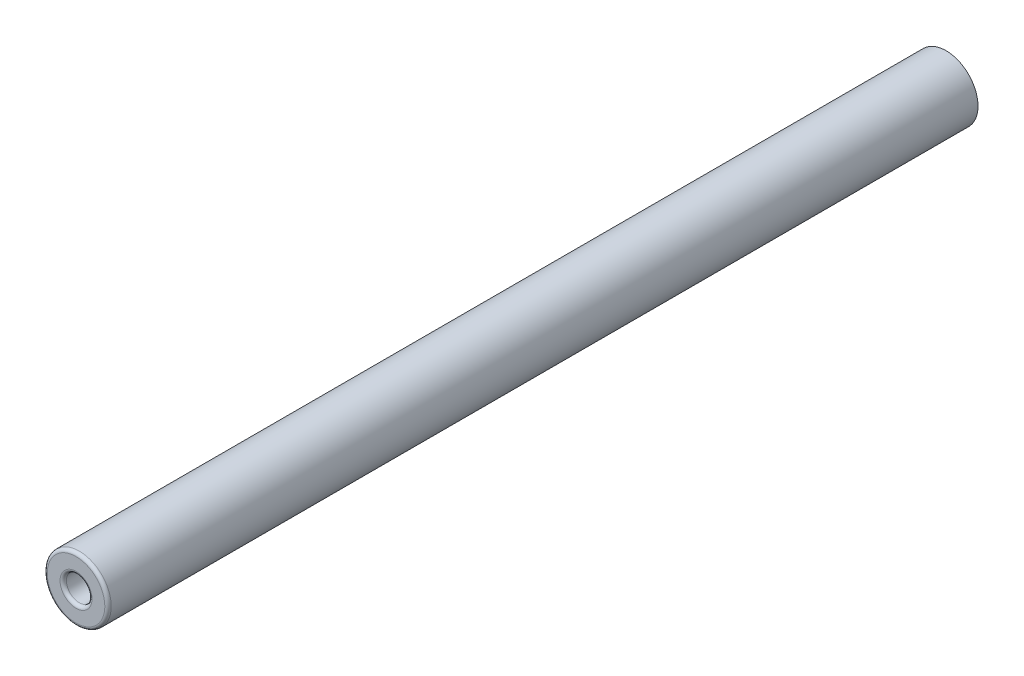
from build123d import *

# Parameters (mm, degrees)
SKETCH1_R           = 2.5
BOSS_EXTRUDE1_DEPTH = 34
SKETCH2_R           = 1
CUT_EXTRUDE1_DEPTH  = 20
FILLET1_R           = 0.25


with BuildPart() as part:
    # Sketch1 → Boss-Extrude1 (new body, symmetric)
    with BuildSketch(Plane.XY):
        Circle(SKETCH1_R)
    extrude(amount=BOSS_EXTRUDE1_DEPTH, both=True)

    # Sketch2 → Cut-Extrude1 (cut)
    with BuildSketch(Plane.XY.offset(34)):
        Circle(SKETCH2_R)
    extrude(amount=-CUT_EXTRUDE1_DEPTH, mode=Mode.SUBTRACT)

    # Fillet1
    fillet1_edges = [part.edges().sort_by_distance(p)[0] for p in [
        (-2.5, 0, 34),
        (-1, 0, 34),
    ]]
    fillet(fillet1_edges, radius=FILLET1_R)


solid = part.part
